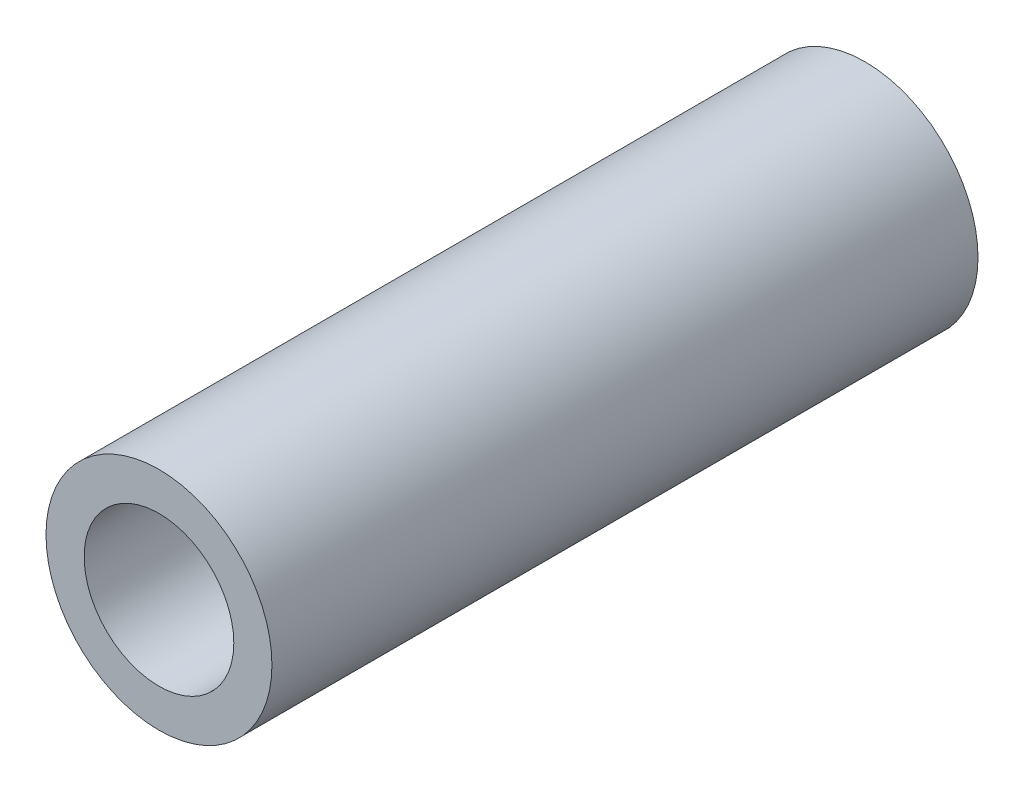
from build123d import *

# Parameters (mm, degrees)
SKETCH1_R      = 4
SKETCH1_R_2    = 2.65
EXTRUDE1_DEPTH = 12.5


with BuildPart() as part:
    # Sketch1 → Extrude1 (new body, symmetric)
    with BuildSketch(Plane.XY):
        Circle(SKETCH1_R)
        Circle(SKETCH1_R_2, mode=Mode.SUBTRACT)
    extrude(amount=EXTRUDE1_DEPTH, both=True)


solid = part.part
